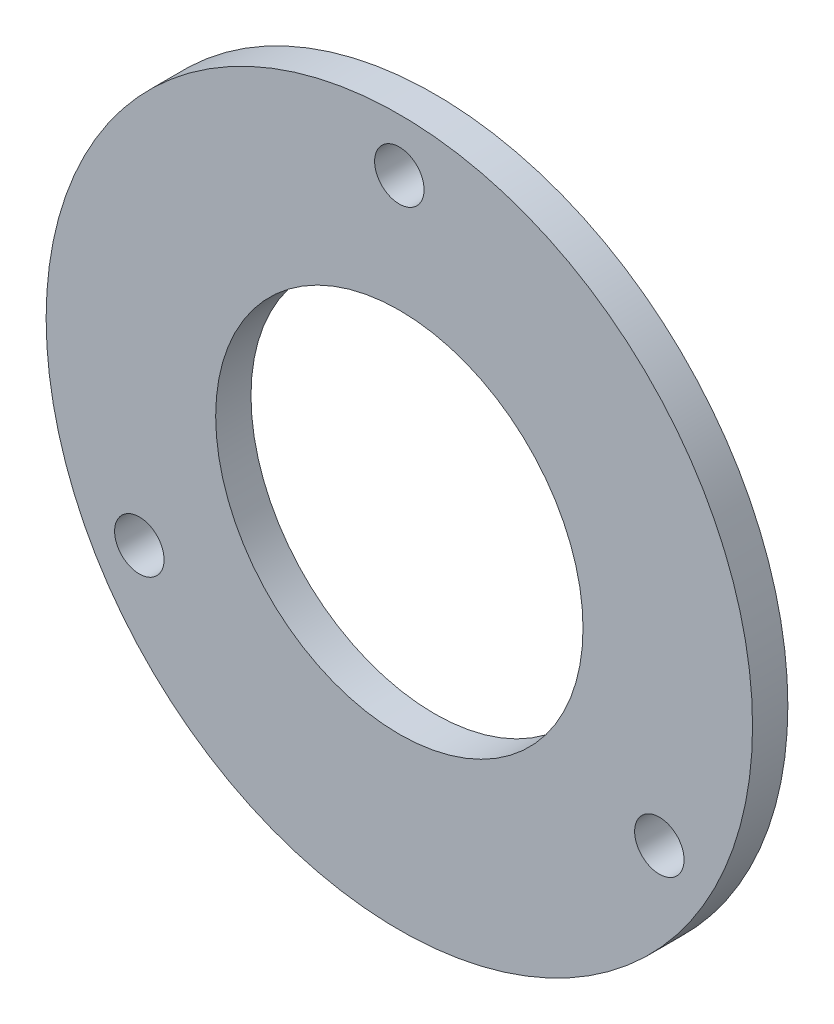
from build123d import *

# Parameters (mm, degrees)
SZKIC1_R                        = 50
SZKIC1_R_2                      = 26
DODANIE_WYCI_GNI_CIE1_DEPTH     = 5
SZKIC3_R                        = 3.5
WYTNIJ_WYCI_GNI_CIE4_DEPTH      = 1
WYTNIJ_WYCI_GNI_CIE4_DEPTH_BACK = 6


with BuildPart() as part:
    # Szkic1 → Dodanie-wyciągnięcie1 (new body)
    with BuildSketch(Plane.XY):
        Circle(SZKIC1_R)
        Circle(SZKIC1_R_2, mode=Mode.SUBTRACT)
    extrude(amount=DODANIE_WYCI_GNI_CIE1_DEPTH)

    # Szkic3 → Wytnij-wyciągnięcie4 (cut, two sides)
    with BuildSketch(Plane.XY.offset(5)) as wytnij_wyci_gni_cie4_sk:
        with Locations((0, 42.5)):
            Circle(SZKIC3_R)
        with Locations((36.806079661, -21.25)):
            Circle(SZKIC3_R)
        with Locations((-36.806079661, -21.25)):
            Circle(SZKIC3_R)
    extrude(amount=WYTNIJ_WYCI_GNI_CIE4_DEPTH, mode=Mode.SUBTRACT)
    extrude(wytnij_wyci_gni_cie4_sk.sketch, amount=-WYTNIJ_WYCI_GNI_CIE4_DEPTH_BACK, mode=Mode.SUBTRACT)


solid = part.part
